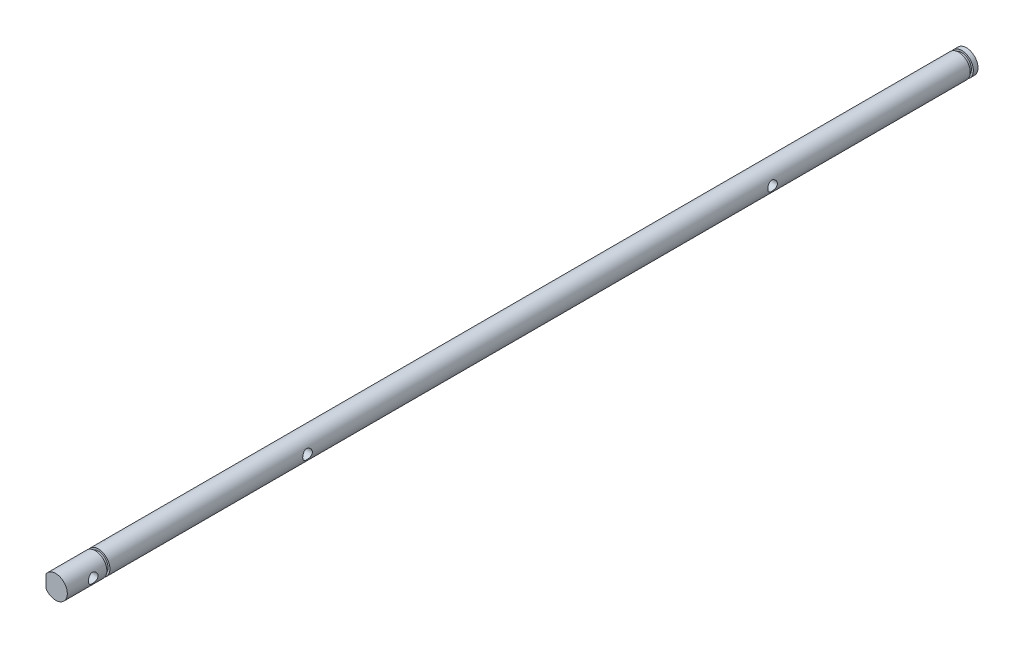
from build123d import *

# Parameters (mm, degrees)
SKETCH1_R               = 3
BOSS_EXTRUDE1_DEPTH     = 235
SKETCH2_W               = 0.5
SKETCH2_H               = 0.8
CUT_EXTRUDE1_DEPTH      = 10
CUT_EXTRUDE1_DEPTH_BACK = 10
SKETCH3_W               = 0.5
SKETCH3_H               = 10
SKETCH3_H_2             = 9
M3_TAPPED_HOLE1_D       = 2.5
M3X0_5_TAPPED_HOLE1_D   = 2.5


with BuildPart() as part:
    # Sketch1 → Boss-Extrude1 (new body)
    with BuildSketch(Plane.XY):
        Circle(SKETCH1_R)
    extrude(amount=BOSS_EXTRUDE1_DEPTH)

    # Sketch2 → Cut-Revolve1 (revolve, cut)
    with BuildSketch(Plane(origin=(0, 0, 0), x_dir=(1, 0, 0), z_dir=(0, 1, 0))):
        with Locations((-2.75, -1.6)):
            Rectangle(SKETCH2_W, SKETCH2_H)
        with Locations((-2.75, -224.4)):
            Rectangle(SKETCH2_W, SKETCH2_H)
    revolve(axis=Axis((0, 0, 240), (0, 0, -1)), mode=Mode.SUBTRACT)

    # Sketch3 → Cut-Extrude1 (cut, two sides: drawn at the far end of the back side and taken through both)
    with BuildSketch(Plane(origin=(0, 0, 0), x_dir=(1, 0, 0), z_dir=(0, 1, 0)).offset(-CUT_EXTRUDE1_DEPTH_BACK)):
        with Locations((-2.75, -53)):
            Rectangle(SKETCH3_W, SKETCH3_H)
        with Locations((-2.75, -173)):
            Rectangle(SKETCH3_W, SKETCH3_H)
        with Locations((-2.75, -230.5)):
            Rectangle(SKETCH3_W, SKETCH3_H_2)
    extrude(amount=CUT_EXTRUDE1_DEPTH + CUT_EXTRUDE1_DEPTH_BACK, mode=Mode.SUBTRACT)

    # M3 Tapped Hole1 (through all)
    with Locations(Plane(origin=(-2.5, 0, 173), x_dir=(0, 0, -1), z_dir=(-1, 0, 0))):
        with Locations((0, 0), (120, 0)):
            Hole(M3_TAPPED_HOLE1_D / 2)

    # M3x0.5 Tapped Hole1 (through all)
    with Locations(Plane(origin=(-2.5, 0, 228.3), x_dir=(0, 0, -1), z_dir=(-1, 0, 0))):
        with Locations((0, 0)):
            Hole(M3X0_5_TAPPED_HOLE1_D / 2)


solid = part.part
